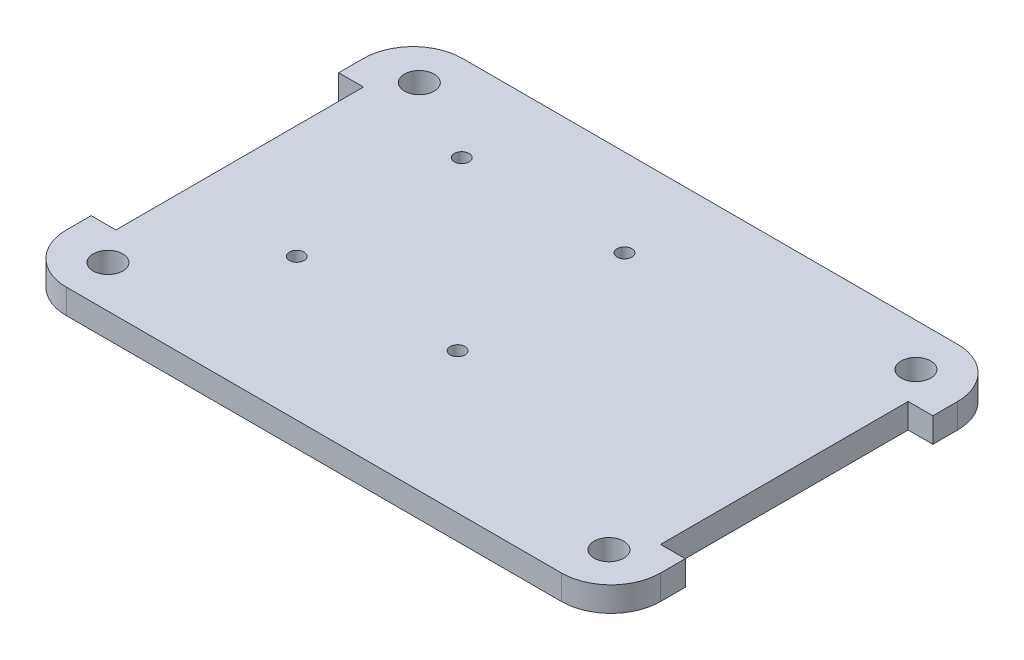
from build123d import *

# Parameters (mm, degrees)
BOSS_EXTRUDE1_DEPTH = 5
SKETCH2_R           = 3
SKETCH2_R_2         = 3.002001364
SKETCH2_R_3         = 2.999925667
SKETCH2_R_4         = 2.998527559
CUT_EXTRUDE2_DEPTH  = 5
SKETCH14_R          = 1.488706827
SKETCH14_R_2        = 1.489546346
SKETCH14_R_3        = 1.489389331
SKETCH14_R_4        = 1.489192683
CUT_EXTRUDE3_DEPTH  = 5


with BuildPart() as part:
    # Sketch1 → Boss-Extrude1 (new body)
    with BuildSketch(Plane(origin=(0, 0, 0), x_dir=(1, 0, 0), z_dir=(0, 1, 0))):
        with BuildLine():
            Line((10, 0), (110, 0))
            ThreePointArc((110, 0), (117.071067812, -2.928932188), (120, -10))
            Line((120, -10), (120, -15))
            Line((120, -15), (115, -15))
            Line((115, -15), (115, -65))
            Line((115, -65), (120, -65))
            Line((120, -65), (120, -70))
            ThreePointArc((120, -70), (117.071067812, -77.071067812), (110, -80))
            Line((110, -80), (10, -80))
            ThreePointArc((10, -80), (2.928932188, -77.071067812), (0, -70))
            Line((0, -70), (0, -65))
            Line((0, -65), (5, -65))
            Line((5, -65), (5, -15))
            Line((5, -15), (0, -15))
            Line((0, -15), (0, -10))
            ThreePointArc((0, -10), (2.928932188, -2.928932188), (10, 0))
        make_face()
    extrude(amount=BOSS_EXTRUDE1_DEPTH)

    # Sketch2 → Cut-Extrude2 (cut)
    with BuildSketch(Plane(origin=(0, 5, 0), x_dir=(1, 0, 0), z_dir=(0, 1, 0))):
        with Locations((9.871405569, -8.58955783)):
            Circle(SKETCH2_R)
        with Locations((9.87978839, -71.481609293)):
            Circle(SKETCH2_R_2)
        with Locations((110.711521692, -71.131223036)):
            Circle(SKETCH2_R_3)
        with Locations((110.199519212, -8.625779617)):
            Circle(SKETCH2_R_4)
    extrude(amount=-CUT_EXTRUDE2_DEPTH, mode=Mode.SUBTRACT)

    # Sketch14 → Cut-Extrude3 (cut)
    with BuildSketch(Plane(origin=(0, 5, 0), x_dir=(1, 0, 0), z_dir=(0, 1, 0))):
        with Locations((27.278668434, -17.438830443)):
            Circle(SKETCH14_R)
        with Locations((60.371161684, -17.660103474)):
            Circle(SKETCH14_R_2)
        with Locations((27.872388447, -51.343688287)):
            Circle(SKETCH14_R_3)
        with Locations((60.628260138, -51.620538185)):
            Circle(SKETCH14_R_4)
    extrude(amount=-CUT_EXTRUDE3_DEPTH, mode=Mode.SUBTRACT)


solid = part.part
